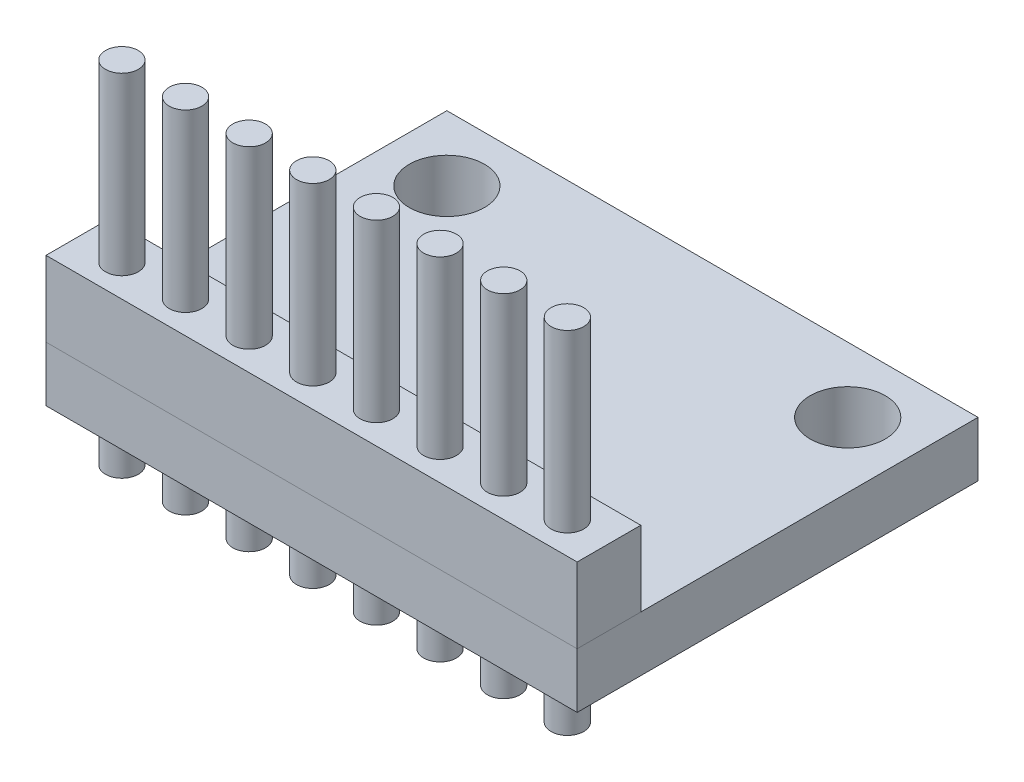
from build123d import *

# Parameters (mm, degrees)
SKETCH1_W                = 21.2
SKETCH1_H                = 16
BOSS_EXTRUDE1_DEPTH      = 2.2
SKETCH2_R                = 1.5
CUT_EXTRUDE1_DEPTH       = 2.2
SKETCH3_R                = 0.653464603
BOSS_EXTRUDE2_DEPTH      = 10
BOSS_EXTRUDE2_DEPTH_BACK = 4
SKETCH4_W                = 21.2
SKETCH4_H                = 2.54
BOSS_EXTRUDE3_DEPTH      = 3
SKETCH5_W                = 4.85373887
SKETCH5_H                = 4.013612747
BOSS_EXTRUDE4_DEPTH      = 1


with BuildPart() as part:
    # Sketch1 → Boss-Extrude1 (new body)
    with BuildSketch(Plane(origin=(0, 0, 0), x_dir=(1, 0, 0), z_dir=(0, 1, 0))):
        with Locations((1.932941176, -1.452941176)):
            Rectangle(SKETCH1_W, SKETCH1_H)
    extrude(amount=BOSS_EXTRUDE1_DEPTH)

    # Sketch2 → Cut-Extrude1 (cut)
    with BuildSketch(Plane(origin=(0, 2.2, 0), x_dir=(1, 0, 0), z_dir=(0, 1, 0))):
        with Locations((-6.067058824, 3.947058824)):
            Circle(SKETCH2_R)
        with Locations((9.932941176, 3.947058824)):
            Circle(SKETCH2_R)
    extrude(amount=-CUT_EXTRUDE1_DEPTH, mode=Mode.SUBTRACT)

    # Sketch3 → Boss-Extrude2 (add, two sides)
    with BuildSketch(Plane(origin=(0, 2.2, 0), x_dir=(1, 0, 0), z_dir=(0, 1, 0))) as boss_extrude2_sk:
        with Locations((-6.907058824, -8.182941176)):
            Circle(SKETCH3_R)
        with Locations((-4.367058824, -8.182941176)):
            Circle(SKETCH3_R)
        with Locations((-1.827058824, -8.182941176)):
            Circle(SKETCH3_R)
        with Locations((0.712941176, -8.182941176)):
            Circle(SKETCH3_R)
        with Locations((3.252941176, -8.182941176)):
            Circle(SKETCH3_R)
        with Locations((5.792941176, -8.182941176)):
            Circle(SKETCH3_R)
        with Locations((8.332941176, -8.182941176)):
            Circle(SKETCH3_R)
        with Locations((10.872941176, -8.182941176)):
            Circle(SKETCH3_R)
    extrude(amount=BOSS_EXTRUDE2_DEPTH)
    extrude(boss_extrude2_sk.sketch, amount=-BOSS_EXTRUDE2_DEPTH_BACK)

    # Sketch5 → Boss-Extrude4 (add)
    with BuildSketch(Plane.XZ):
        with Locations((1.248041988, 1.655101133)):
            Rectangle(SKETCH5_W, SKETCH5_H)
    extrude(amount=BOSS_EXTRUDE4_DEPTH)


with BuildPart() as body_2:
    # Sketch4 → Boss-Extrude3 (new body)
    with BuildSketch(Plane(origin=(0, 2.2, 0), x_dir=(1, 0, 0), z_dir=(0, 1, 0))):
        with Locations((1.932941176, -8.182941176)):
            Rectangle(SKETCH4_W, SKETCH4_H)
    extrude(amount=BOSS_EXTRUDE3_DEPTH)


solid = Compound([part.part, body_2.part])
